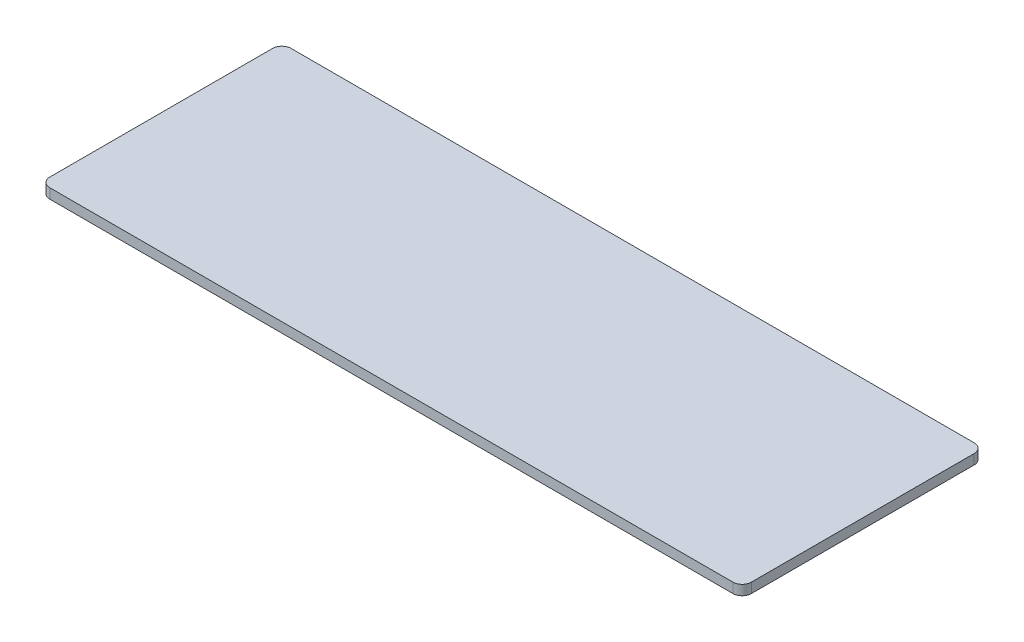
from build123d import *

# Parameters (mm, degrees)
SKETCH2_W           = 75.6
SKETCH2_H           = 26
BOSS_EXTRUDE1_DEPTH = 0.535
FILLET1_R           = 1


with BuildPart() as part:
    # Sketch2 → Boss-Extrude1 (new body, symmetric)
    with BuildSketch(Plane(origin=(0, 0, 0), x_dir=(1, 0, 0), z_dir=(0, 1, 0))):
        Rectangle(SKETCH2_W, SKETCH2_H)
    extrude(amount=BOSS_EXTRUDE1_DEPTH, both=True)

    # Fillet1
    fillet1_edges = [part.edges().sort_by_distance(p)[0] for p in [
        (-37.8, 0, -13),
        (37.8, 0, -13),
        (37.8, 0, 13),
        (-37.8, 0, 13),
    ]]
    fillet(fillet1_edges, radius=FILLET1_R)


solid = part.part
